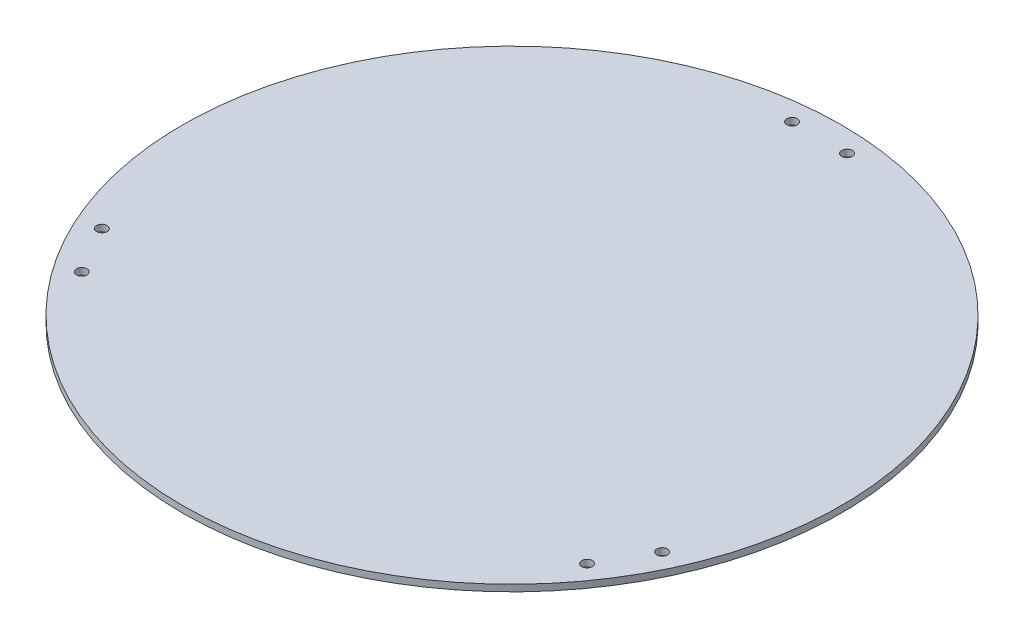
from build123d import *

# Parameters (mm, degrees)
SKETCH1_R           = 150
SKETCH1_R_2         = 2.4
BOSS_EXTRUDE1_DEPTH = 3


with BuildPart() as part:
    # Sketch1 → Boss-Extrude1 (new body)
    with BuildSketch(Plane(origin=(0, 0, 0), x_dir=(1, 0, 0), z_dir=(0, 1, 0))):
        Circle(SKETCH1_R)
        with Locations((12.5, 140)):
            Circle(SKETCH1_R_2, mode=Mode.SUBTRACT)
        with Locations((-12.5, 140)):
            Circle(SKETCH1_R_2, mode=Mode.SUBTRACT)
        with Locations((127.49355653, -59.174682453)):
            Circle(SKETCH1_R_2, mode=Mode.SUBTRACT)
        with Locations((114.99355653, -80.825317547)):
            Circle(SKETCH1_R_2, mode=Mode.SUBTRACT)
        with Locations((-114.99355653, -80.825317547)):
            Circle(SKETCH1_R_2, mode=Mode.SUBTRACT)
        with Locations((-127.49355653, -59.174682453)):
            Circle(SKETCH1_R_2, mode=Mode.SUBTRACT)
    extrude(amount=BOSS_EXTRUDE1_DEPTH)


solid = part.part
